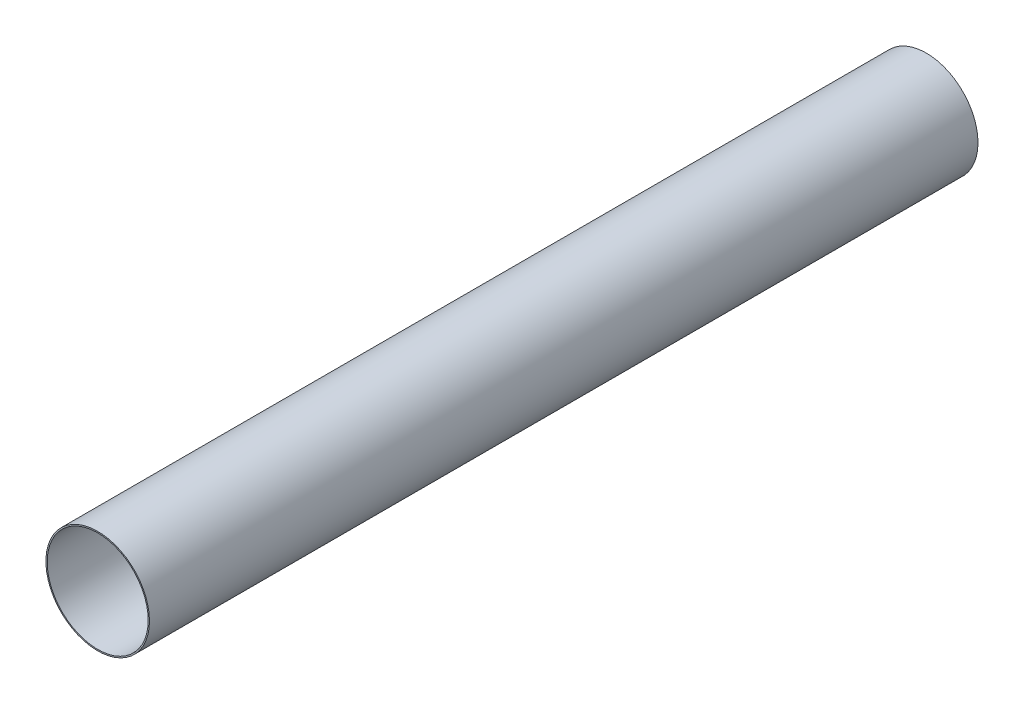
from build123d import *

# Parameters (mm, degrees)
SKETCH1_R           = 20.6375
SKETCH1_R_2         = 20.1295
BOSS_EXTRUDE1_DEPTH = 330.2


with BuildPart() as part:
    # Sketch1 → Boss-Extrude1 (new body)
    with BuildSketch(Plane.XY):
        Circle(SKETCH1_R)
        Circle(SKETCH1_R_2, mode=Mode.SUBTRACT)
    extrude(amount=BOSS_EXTRUDE1_DEPTH)


solid = part.part
